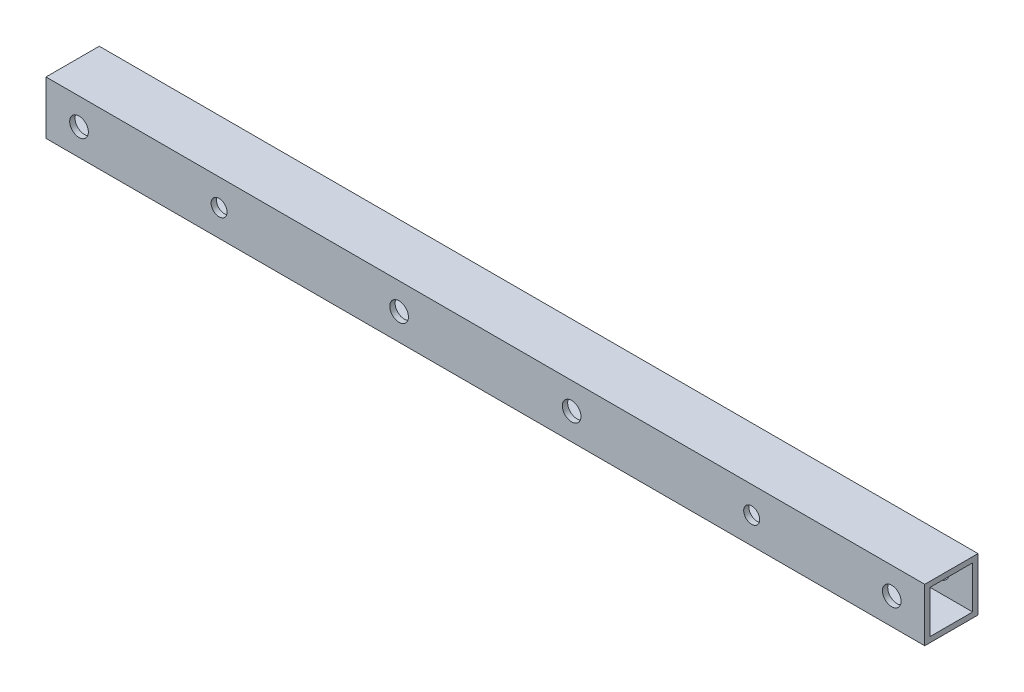
from build123d import *

# Parameters (mm, degrees)
SKETCH_2_W          = 10
SKETCH_2_H          = 10
SKETCH_2_W_2        = 8
SKETCH_2_H_2        = 8
EXTRUDE_1_DEPTH     = 165
SKETCH_3_R          = 1.75
SKETCH_3_R_2        = 1.5
CUT_EXTRUDE_1_DEPTH = 11


with BuildPart() as part:
    # 草图2 → 拉伸-薄壁1 (new body)
    with BuildSketch(Plane(origin=(0, 0, 0), x_dir=(0, 0, -1), z_dir=(1, 0, 0))):
        Rectangle(SKETCH_2_W, SKETCH_2_H)
        Rectangle(SKETCH_2_W_2, SKETCH_2_H_2, mode=Mode.SUBTRACT)
    extrude(amount=-EXTRUDE_1_DEPTH)

    # 草图3 → 切除-拉伸1 (cut, through all)
    with BuildSketch(Plane.XY.offset(5)):
        with Locations((-6.2, 0)):
            Circle(SKETCH_3_R)
        with Locations((-158.8, 0)):
            Circle(SKETCH_3_R)
        with Locations((-32.5, 0)):
            Circle(SKETCH_3_R_2)
        with Locations((-132.5, 0)):
            Circle(SKETCH_3_R_2)
        with Locations((-66.3, 0)):
            Circle(SKETCH_3_R)
        with Locations((-98.7, 0)):
            Circle(SKETCH_3_R)
    extrude(amount=-CUT_EXTRUDE_1_DEPTH, mode=Mode.SUBTRACT)


solid = part.part
